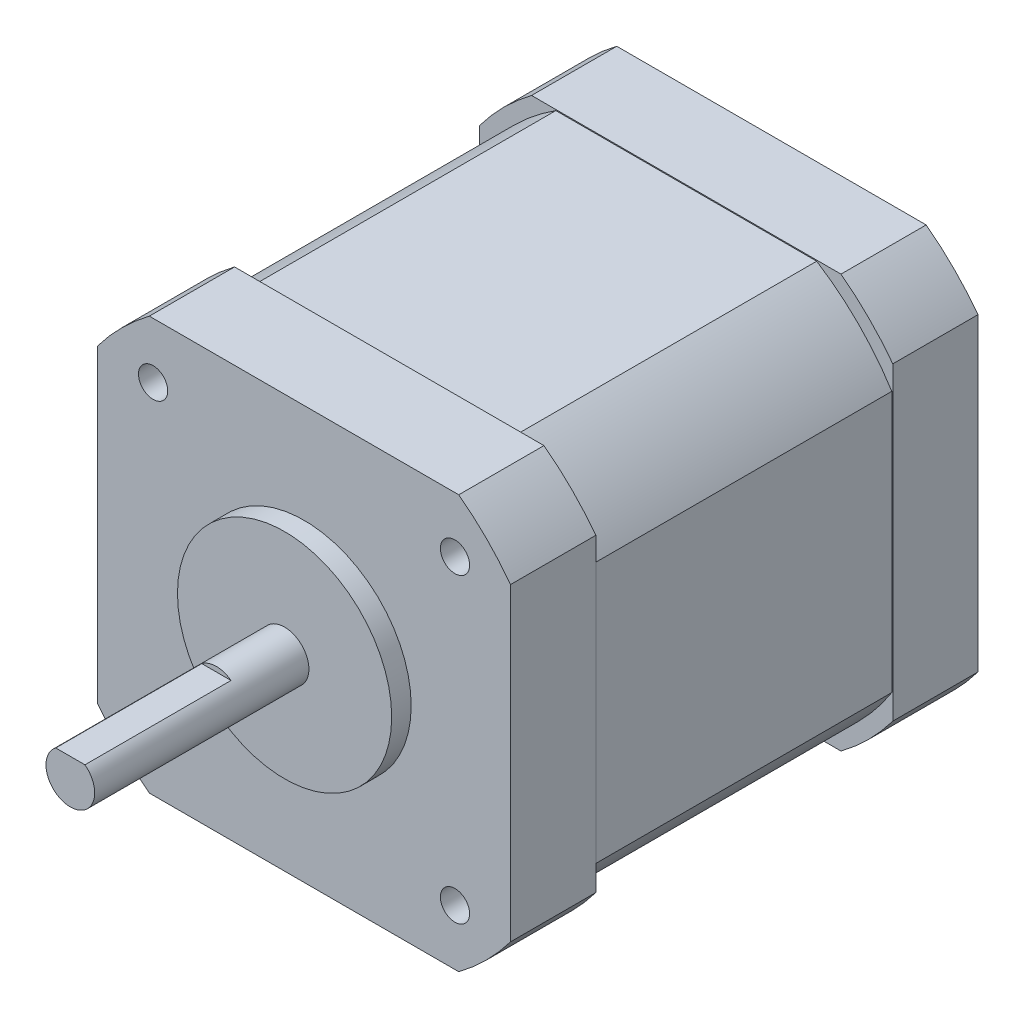
from build123d import *

# Parameters (mm, degrees)
SKETCH1_R                       = 2.5
BOSS_EXTRUDE1_DEPTH             = 24
SKETCH2_R                       = 11
BOSS_EXTRUDE2_DEPTH             = 2
SKETCH3_W                       = 42.418
SKETCH3_H                       = 42.418
BOSS_EXTRUDE3_DEPTH             = 48
CUT_EXTRUDE1_DEPTH              = 73
M3X0_5_TAPPED_HOLE1_D           = 2.5
M3X0_5_TAPPED_HOLE1_DEPTH       = 7.5
M3X0_5_TAPPED_HOLE1_CBORE_D     = 3
M3X0_5_TAPPED_HOLE1_CBORE_DEPTH = 6
M3X0_5_TAPPED_HOLE1_TIP         = 0.751075774
CUT_EXTRUDE2_DEPTH              = 15
CUT_EXTRUDE3_DEPTH              = 15.25
CUT_EXTRUDE3_DEPTH_BACK         = 15.25


with BuildPart() as part:
    # Sketch1 → Boss-Extrude1 (new body)
    with BuildSketch(Plane.XY):
        Circle(SKETCH1_R)
    extrude(amount=BOSS_EXTRUDE1_DEPTH)

    # Sketch2 → Boss-Extrude2 (add)
    with BuildSketch(Plane(origin=(0, 0, 0), x_dir=(-1, 0, 0), z_dir=(0, 0, -1))):
        Circle(SKETCH2_R)
    extrude(amount=-BOSS_EXTRUDE2_DEPTH)

    # Sketch3 → Boss-Extrude3 (add)
    with BuildSketch(Plane(origin=(0, 0, 0), x_dir=(-1, 0, 0), z_dir=(0, 0, -1))):
        Rectangle(SKETCH3_W, SKETCH3_H)
    extrude(amount=BOSS_EXTRUDE3_DEPTH)

    # Sketch4 → Cut-Extrude1 (cut, through all)
    with BuildSketch(Plane(origin=(0, 0, -48), x_dir=(-1, 0, 0), z_dir=(0, 0, -1))):
        with BuildLine():
            Line((-21.209, -15.887992919), (-21.209, -21.209))
            Line((-21.209, -21.209), (-15.887992919, -21.209))
            ThreePointArc((-15.887992919, -21.209), (-18.738329701, -18.738329701), (-21.209, -15.887992919))
        make_face()
        with BuildLine():
            Line((15.887992919, -21.209), (21.209, -21.209))
            Line((21.209, -21.209), (21.209, -15.887992919))
            ThreePointArc((21.209, -15.887992919), (18.738329701, -18.738329701), (15.887992919, -21.209))
        make_face()
        with BuildLine():
            Line((21.209, 15.887992919), (21.209, 21.209))
            Line((21.209, 21.209), (15.887992919, 21.209))
            ThreePointArc((15.887992919, 21.209), (18.738329701, 18.738329701), (21.209, 15.887992919))
        make_face()
        with BuildLine():
            Line((-15.887992919, 21.209), (-21.209, 21.209))
            Line((-21.209, 21.209), (-21.209, 15.887992919))
            ThreePointArc((-21.209, 15.887992919), (-18.738329701, 18.738329701), (-15.887992919, 21.209))
        make_face()
    extrude(amount=-CUT_EXTRUDE1_DEPTH, mode=Mode.SUBTRACT)

    # M3x0.5 Tapped Hole1
    with Locations(Plane.XY):
        with Locations((-15.5, 15.5), (-15.5, -15.5), (15.5, -15.5), (15.5, 15.5)):
            CounterBoreHole(M3X0_5_TAPPED_HOLE1_D / 2, M3X0_5_TAPPED_HOLE1_CBORE_D / 2, M3X0_5_TAPPED_HOLE1_CBORE_DEPTH, depth=M3X0_5_TAPPED_HOLE1_DEPTH)
            with Locations((0, 0, -(M3X0_5_TAPPED_HOLE1_DEPTH + M3X0_5_TAPPED_HOLE1_TIP / 2))):  # 118° drill point
                Cone(0, M3X0_5_TAPPED_HOLE1_D / 2, M3X0_5_TAPPED_HOLE1_TIP, mode=Mode.SUBTRACT)

    # Sketch7 → Cut-Extrude2 (cut)
    with BuildSketch(Plane.XY.offset(24)):
        with BuildLine():
            Line((-1.5, 2), (1.5, 2))
            ThreePointArc((1.5, 2), (0, 2.5), (-1.5, 2))
        make_face()
    extrude(amount=-CUT_EXTRUDE2_DEPTH, mode=Mode.SUBTRACT)

    # Sketch8 → Cut-Extrude3 (cut, two sides)
    with BuildSketch(Plane.XY.offset(-24)) as cut_extrude3_sk:
        with BuildLine():
            Line((15.887992919, 21.209), (-15.887992919, 21.209))
            ThreePointArc((-15.887992919, 21.209), (-18.738329701, 18.738329701), (-21.209, 15.887992919))
            Line((-21.209, 15.887992919), (-21.209, -15.887992919))
            ThreePointArc((-21.209, -15.887992919), (-18.738329701, -18.738329701), (-15.887992919, -21.209))
            Line((-15.887992919, -21.209), (15.887992919, -21.209))
            ThreePointArc((15.887992919, -21.209), (18.738329701, -18.738329701), (21.209, -15.887992919))
            Line((21.209, -15.887992919), (21.209, 15.887992919))
            ThreePointArc((21.209, 15.887992919), (18.738329701, 18.738329701), (15.887992919, 21.209))
        make_face()
        with BuildLine():
            Line((-13.394406258, 21.109), (13.394406258, 21.109))
            ThreePointArc((13.394406258, 21.109), (17.67766953, 17.67766953), (21.109, 13.394406258))
            Line((21.109, 13.394406258), (21.109, -13.394406258))
            ThreePointArc((21.109, -13.394406258), (17.67766953, -17.67766953), (13.394406258, -21.109))
            Line((13.394406258, -21.109), (-13.394406258, -21.109))
            ThreePointArc((-13.394406258, -21.109), (-17.67766953, -17.67766953), (-21.109, -13.394406258))
            Line((-21.109, -13.394406258), (-21.109, 13.394406258))
            ThreePointArc((-21.109, 13.394406258), (-17.67766953, 17.67766953), (-13.394406258, 21.109))
        make_face(mode=Mode.SUBTRACT)
    extrude(amount=CUT_EXTRUDE3_DEPTH, mode=Mode.SUBTRACT)
    extrude(cut_extrude3_sk.sketch, amount=-CUT_EXTRUDE3_DEPTH_BACK, mode=Mode.SUBTRACT)


solid = part.part
